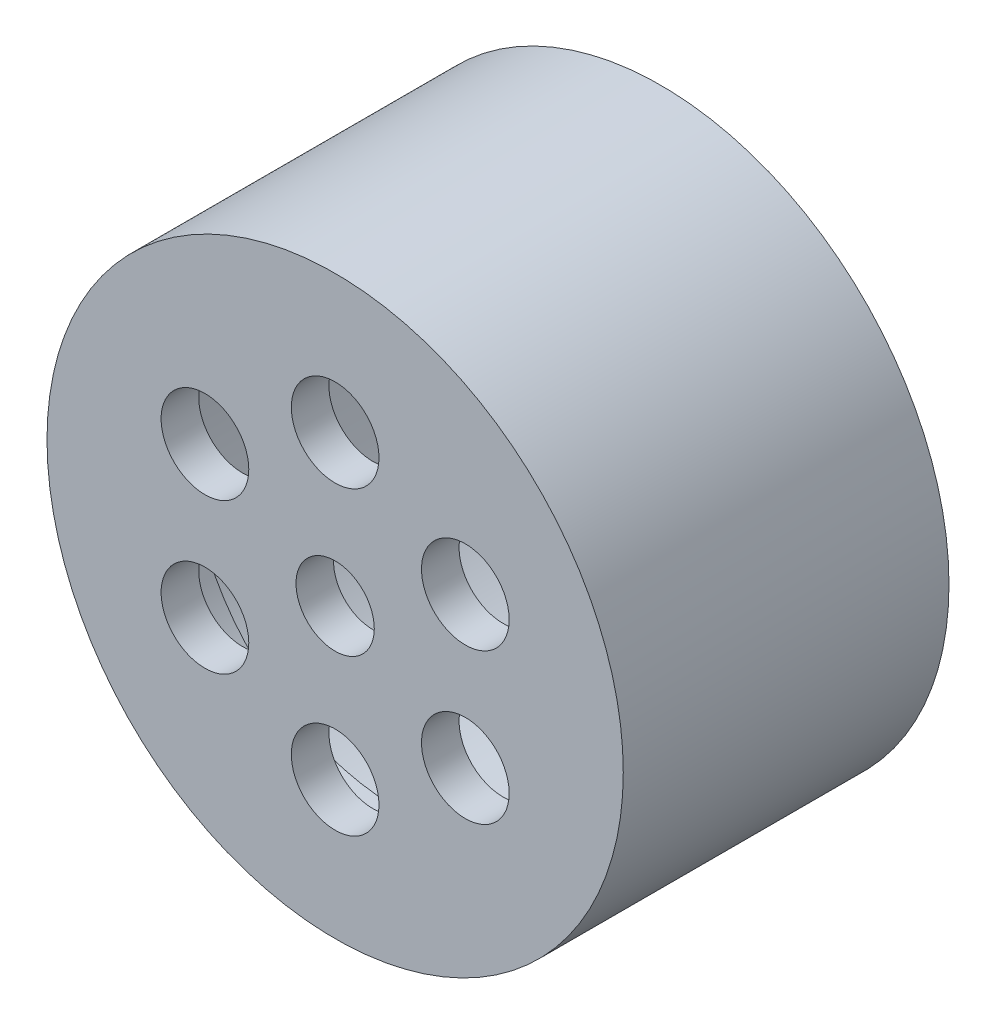
from build123d import *

# Parameters (mm, degrees)
CROQUIS1_R              = 23
CROQUIS1_R_2            = 21
SALIENTE_EXTRUIR1_DEPTH = 23
CROQUIS2_R              = 23
CROQUIS2_R_2            = 3.125
CROQUIS2_R_3            = 3.5
SALIENTE_EXTRUIR2_DEPTH = 3
CROQUIS3_R              = 21
CROQUIS3_R_2            = 16.5
SALIENTE_EXTRUIR3_DEPTH = 2


with BuildPart() as part:
    # Croquis1 → Saliente-Extruir1 (new body)
    with BuildSketch(Plane.XY):
        Circle(CROQUIS1_R)
        Circle(CROQUIS1_R_2, mode=Mode.SUBTRACT)
    extrude(amount=SALIENTE_EXTRUIR1_DEPTH)

    # Croquis2 → Saliente-Extruir2 (add)
    with BuildSketch(Plane.XY.offset(23)):
        Circle(CROQUIS2_R)
        Circle(CROQUIS2_R_2, mode=Mode.SUBTRACT)
        with Locations((0, 12)):
            Circle(CROQUIS2_R_3, mode=Mode.SUBTRACT)
        with Locations((10.392304845, 6)):
            Circle(CROQUIS2_R_3, mode=Mode.SUBTRACT)
        with Locations((10.392304845, -6)):
            Circle(CROQUIS2_R_3, mode=Mode.SUBTRACT)
        with Locations((0, -12)):
            Circle(CROQUIS2_R_3, mode=Mode.SUBTRACT)
        with Locations((-10.392304845, -6)):
            Circle(CROQUIS2_R_3, mode=Mode.SUBTRACT)
        with Locations((-10.392304845, 6)):
            Circle(CROQUIS2_R_3, mode=Mode.SUBTRACT)
    extrude(amount=SALIENTE_EXTRUIR2_DEPTH)

    # Croquis3 → Saliente-Extruir3 (add)
    with BuildSketch(Plane(origin=(0, 0, 23), x_dir=(-1, 0, 0), z_dir=(0, 0, -1))):
        Circle(CROQUIS3_R)
        Circle(CROQUIS3_R_2, mode=Mode.SUBTRACT)
    extrude(amount=SALIENTE_EXTRUIR3_DEPTH)


solid = part.part
